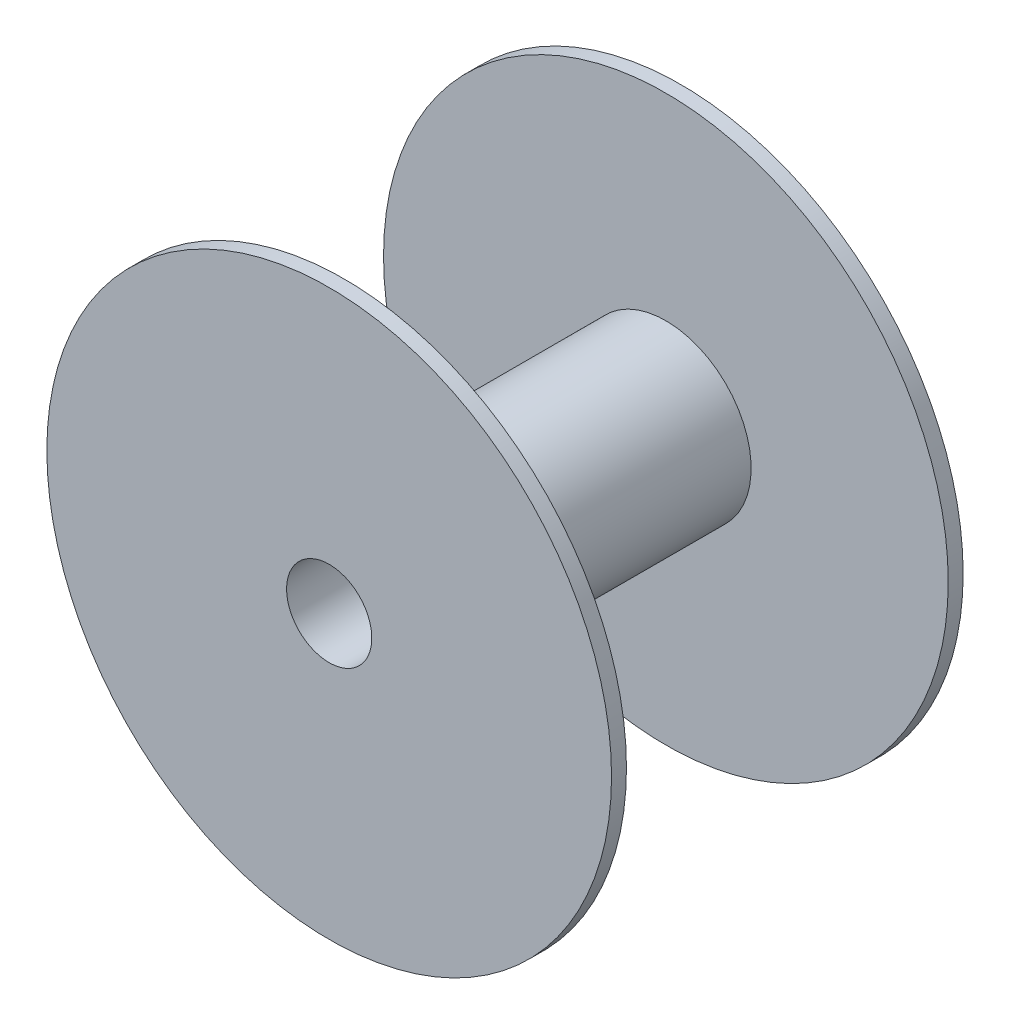
from build123d import *

# Parameters (mm, degrees)
SKETCH_1_R          = 80
EXTRUDE_1_DEPTH     = 302
SKETCH_2_R          = 265
EXTRUDE_2_DEPTH     = 14
SKETCH_3_R          = 265
EXTRUDE_3_DEPTH     = 14
SKETCH_4_R          = 40
CUT_EXTRUDE_1_DEPTH = 331


with BuildPart() as part:
    # Эскиз1 → Бобышка-Вытянуть1 (new body)
    with BuildSketch(Plane.XY):
        Circle(SKETCH_1_R)
    extrude(amount=EXTRUDE_1_DEPTH)

    # Эскиз2 → Бобышка-Вытянуть2 (add)
    with BuildSketch(Plane(origin=(0, 0, 0), x_dir=(-1, 0, 0), z_dir=(0, 0, -1))):
        Circle(SKETCH_2_R)
    extrude(amount=EXTRUDE_2_DEPTH)

    # Эскиз3 → Бобышка-Вытянуть3 (add)
    with BuildSketch(Plane.XY.offset(302)):
        Circle(SKETCH_3_R)
    extrude(amount=EXTRUDE_3_DEPTH)

    # Эскиз4 → Вырез-Вытянуть1 (cut, through all)
    with BuildSketch(Plane(origin=(0, 0, -14), x_dir=(-1, 0, 0), z_dir=(0, 0, -1))):
        Circle(SKETCH_4_R)
    extrude(amount=-CUT_EXTRUDE_1_DEPTH, mode=Mode.SUBTRACT)


solid = part.part
